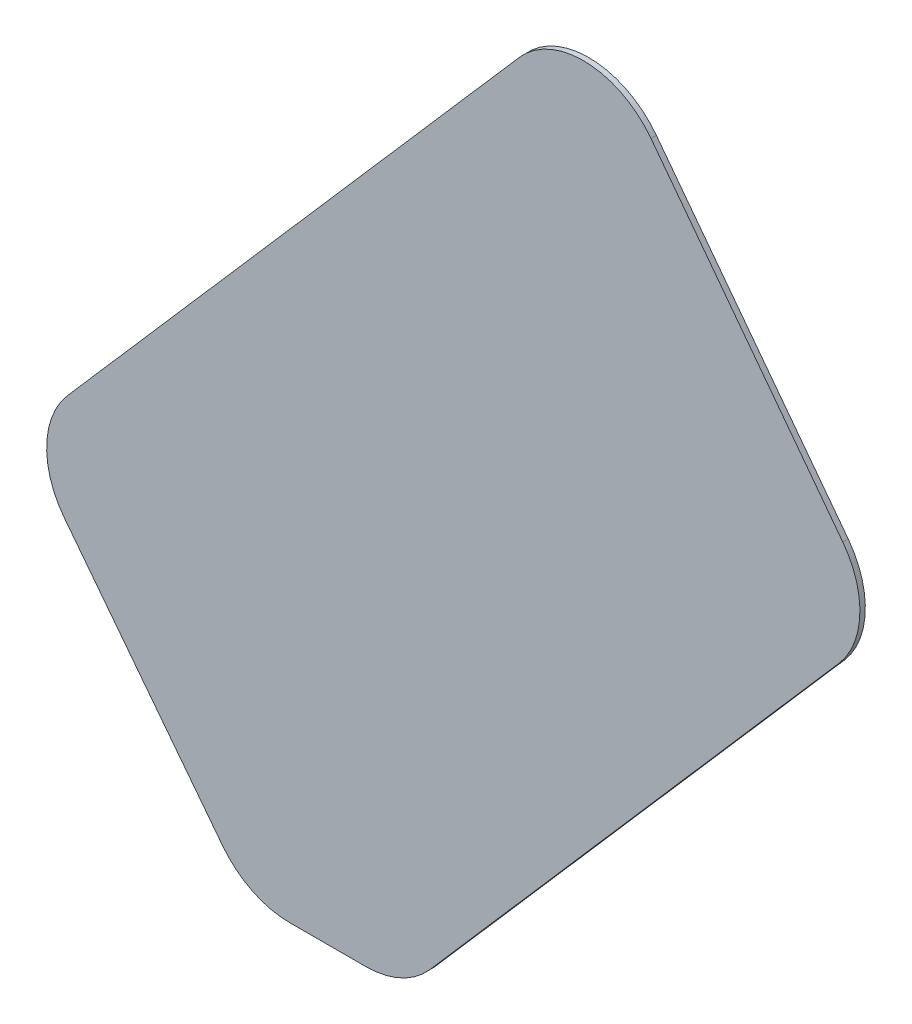
from build123d import *

# Parameters (mm, degrees)
BOSS_EXTRUDE1_DEPTH = 1.5875
SCALE1_SCALE        = 0.8


with BuildPart() as part:
    # Sketch1 → Boss-Extrude1 (new body, symmetric)
    with BuildSketch(Plane.XY):
        with BuildLine():
            Line((-213.499711216, 186.497468723), (53.01875396, 492.542625266))
            ThreePointArc((53.01875396, 492.542625266), (92.447986648, 509.676487347), (130.603493871, 489.867628503))
            Line((130.603493871, 489.867628503), (243.695621782, 340.341208487))
            ThreePointArc((243.695621782, 340.341208487), (253.7875264, 308.456864193), (241.52355595, 277.343314433))
            Line((241.52355595, 277.343314433), (0, 0))
            ThreePointArc((0, 0), (-16.991876757, -12.670819234), (-37.70633704, -17.163554592))
            Line((-37.70633704, -17.163554592), (-82.399555371, -17.163554592))
            ThreePointArc((-82.399555371, -17.163554592), (-104.434529771, -12.046289615), (-121.959152061, 2.25804928))
            Line((-121.959152061, 2.25804928), (-215.352970866, 123.082627187))
            ThreePointArc((-215.352970866, 123.082627187), (-225.772036229, 155.121618903), (-213.499711216, 186.497468723))
        make_face()
    extrude(amount=BOSS_EXTRUDE1_DEPTH, both=True)


with BuildPart() as part_1:
    # Scale1: scaled about (0, 0, 0)
    add(part.part.scale(SCALE1_SCALE))


solid = part_1.part
